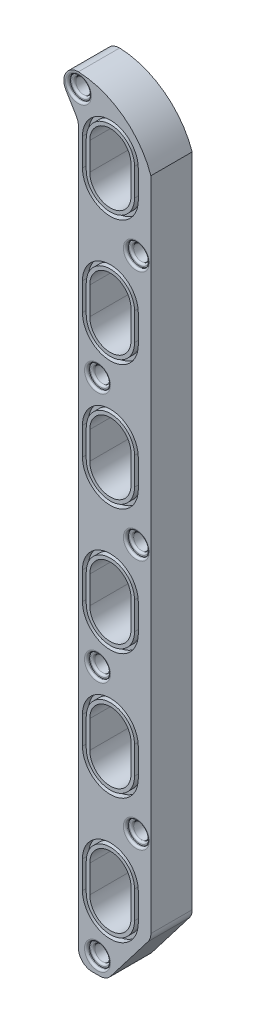
from build123d import *

# Parameters (mm, degrees)
BASE_FLANGE_GEOMETRY_R   = 5.6
BOSS_EXTRUDE1_DEPTH      = 4.35
BOSS_EXTRUDE1_2_DEPTH    = 4.35
BOSS_EXTRUDE1_3_DEPTH    = 4.35
BOSS_EXTRUDE1_4_DEPTH    = 4.35
BOSS_EXTRUDE1_5_DEPTH    = 4.35
BOSS_EXTRUDE1_6_DEPTH    = 4.35
BOSS_EXTRUDE1_7_DEPTH    = 4.35
BOSS_EXTRUDE2_START      = -25.65
BASE_FLANGE_GEOMETRY_5_R = 5.6
BOSS_EXTRUDE2_DEPTH      = 25.65
CHAMFER1_SIZE            = 42
CHAMFER1_SIZE2           = 32.227733495
FILLET1_R                = 10
CUT_EXTRUDE1_START       = -2.2
INSERT_HOLE_GEOMETRY_R   = 7.91
INSERT_HOLE_GEOMETRY_R_2 = 5.6
CUT_EXTRUDE1_DEPTH       = 2.2
FILLET2_R                = 1.5


with BuildPart() as part:
    # Base_Flange_Geometry → Boss-Extrude1 (new body)
    with BuildSketch(Plane(origin=(0, 0, 0), x_dir=(0, 1, 0), z_dir=(0, 0, 1))):
        with BuildLine():
            Line((245.4, 23.25), (-285, 23.25))
            Line((-285, 23.25), (-285, -29.45))
            Line((-285, -29.45), (237.5, -29.45))
            ThreePointArc((237.5, -29.45), (265.150364046, -9.109947518), (276.6, 23.25))
            ThreePointArc((276.6, 23.25), (271.222245174, 32.474324113), (260.545631068, 32.33899662))
            Line((260.545631068, 32.33899662), (245.4, 23.25))
        make_face()
        with Locations((-182, -18.85)):
            Circle(BASE_FLANGE_GEOMETRY_R, mode=Mode.SUBTRACT)
        with BuildLine():
            Line((-237.5, 20.3), (-217.5, 20.3))
            ThreePointArc((-217.5, 20.3), (-197.2, 0), (-217.5, -20.3))
            Line((-217.5, -20.3), (-237.5, -20.3))
            ThreePointArc((-237.5, -20.3), (-257.8, 0), (-237.5, 20.3))
        make_face(mode=Mode.SUBTRACT)
        with BuildLine():
            Line((-146.5, 20.3), (-126.5, 20.3))
            ThreePointArc((-126.5, 20.3), (-106.2, 0), (-126.5, -20.3))
            Line((-126.5, -20.3), (-146.5, -20.3))
            ThreePointArc((-146.5, -20.3), (-166.8, 0), (-146.5, 20.3))
        make_face(mode=Mode.SUBTRACT)
        with BuildLine():
            Line((-55.5, 20.3), (-35.5, 20.3))
            ThreePointArc((-35.5, 20.3), (-15.2, 0), (-35.5, -20.3))
            Line((-35.5, -20.3), (-55.5, -20.3))
            ThreePointArc((-55.5, -20.3), (-75.8, 0), (-55.5, 20.3))
        make_face(mode=Mode.SUBTRACT)
        with Locations((0, -18.85)):
            Circle(BASE_FLANGE_GEOMETRY_R, mode=Mode.SUBTRACT)
        with Locations((182, -18.85)):
            Circle(BASE_FLANGE_GEOMETRY_R, mode=Mode.SUBTRACT)
        with BuildLine():
            ThreePointArc((35.5, -20.3), (15.2, 0), (35.5, 20.3))
            Line((35.5, 20.3), (55.5, 20.3))
            ThreePointArc((55.5, 20.3), (75.8, 0), (55.5, -20.3))
            Line((55.5, -20.3), (35.5, -20.3))
        make_face(mode=Mode.SUBTRACT)
        with BuildLine():
            ThreePointArc((126.5, -20.3), (106.2, 0), (126.5, 20.3))
            Line((126.5, 20.3), (146.5, 20.3))
            ThreePointArc((146.5, 20.3), (166.8, 0), (146.5, -20.3))
            Line((146.5, -20.3), (126.5, -20.3))
        make_face(mode=Mode.SUBTRACT)
        with BuildLine():
            ThreePointArc((217.5, -20.3), (197.2, 0), (217.5, 20.3))
            Line((217.5, 20.3), (237.5, 20.3))
            ThreePointArc((237.5, 20.3), (257.8, 0), (237.5, -20.3))
            Line((237.5, -20.3), (217.5, -20.3))
        make_face(mode=Mode.SUBTRACT)
        with Locations((-273, 9.4)):
            Circle(BASE_FLANGE_GEOMETRY_R, mode=Mode.SUBTRACT)
        with Locations((-91, 9.4)):
            Circle(BASE_FLANGE_GEOMETRY_R, mode=Mode.SUBTRACT)
        with Locations((91, 9.4)):
            Circle(BASE_FLANGE_GEOMETRY_R, mode=Mode.SUBTRACT)
        with Locations((266, 23.25)):
            Circle(BASE_FLANGE_GEOMETRY_R, mode=Mode.SUBTRACT)
    extrude(amount=BOSS_EXTRUDE1_DEPTH)



with BuildPart() as body_2:
    # Base_Flange_Geometry → Boss-Extrude1 2 (new body)
    with BuildSketch(Plane(origin=(0, 0, 0), x_dir=(0, 1, 0), z_dir=(0, 0, 1))):
        with BuildLine():
            Line((237.5, 17.55), (217.5, 17.55))
            ThreePointArc((217.5, 17.55), (199.95, 0), (217.5, -17.55))
            Line((217.5, -17.55), (237.5, -17.55))
            ThreePointArc((237.5, -17.55), (255.05, 0), (237.5, 17.55))
        make_face()
        with BuildLine():
            ThreePointArc((217.5, -15), (202.5, 0), (217.5, 15))
            Line((217.5, 15), (237.5, 15))
            ThreePointArc((237.5, 15), (252.5, 0), (237.5, -15))
            Line((237.5, -15), (217.5, -15))
        make_face(mode=Mode.SUBTRACT)
    extrude(amount=BOSS_EXTRUDE1_2_DEPTH)


with BuildPart() as body_3:
    # Base_Flange_Geometry → Boss-Extrude1 3 (new body)
    with BuildSketch(Plane(origin=(0, 0, 0), x_dir=(0, 1, 0), z_dir=(0, 0, 1))):
        with BuildLine():
            Line((146.5, 17.55), (126.5, 17.55))
            ThreePointArc((126.5, 17.55), (108.95, 0), (126.5, -17.55))
            Line((126.5, -17.55), (146.5, -17.55))
            ThreePointArc((146.5, -17.55), (164.05, 0), (146.5, 17.55))
        make_face()
        with BuildLine():
            ThreePointArc((126.5, -15), (111.5, 0), (126.5, 15))
            Line((126.5, 15), (146.5, 15))
            ThreePointArc((146.5, 15), (161.5, 0), (146.5, -15))
            Line((146.5, -15), (126.5, -15))
        make_face(mode=Mode.SUBTRACT)
    extrude(amount=BOSS_EXTRUDE1_3_DEPTH)


with BuildPart() as body_4:
    # Base_Flange_Geometry → Boss-Extrude1 4 (new body)
    with BuildSketch(Plane(origin=(0, 0, 0), x_dir=(0, 1, 0), z_dir=(0, 0, 1))):
        with BuildLine():
            Line((55.5, 17.55), (35.5, 17.55))
            ThreePointArc((35.5, 17.55), (17.95, 0), (35.5, -17.55))
            Line((35.5, -17.55), (55.5, -17.55))
            ThreePointArc((55.5, -17.55), (73.05, 0), (55.5, 17.55))
        make_face()
        with BuildLine():
            ThreePointArc((35.5, -15), (20.5, 0), (35.5, 15))
            Line((35.5, 15), (55.5, 15))
            ThreePointArc((55.5, 15), (70.5, 0), (55.5, -15))
            Line((55.5, -15), (35.5, -15))
        make_face(mode=Mode.SUBTRACT)
    extrude(amount=BOSS_EXTRUDE1_4_DEPTH)


with BuildPart() as body_5:
    # Base_Flange_Geometry → Boss-Extrude1 5 (new body)
    with BuildSketch(Plane(origin=(0, 0, 0), x_dir=(0, 1, 0), z_dir=(0, 0, 1))):
        with BuildLine():
            ThreePointArc((-35.5, -17.55), (-17.95, 0), (-35.5, 17.55))
            Line((-35.5, 17.55), (-55.5, 17.55))
            ThreePointArc((-55.5, 17.55), (-73.05, 0), (-55.5, -17.55))
            Line((-55.5, -17.55), (-35.5, -17.55))
        make_face()
        with BuildLine():
            Line((-55.5, 15), (-35.5, 15))
            ThreePointArc((-35.5, 15), (-20.5, 0), (-35.5, -15))
            Line((-35.5, -15), (-55.5, -15))
            ThreePointArc((-55.5, -15), (-70.5, 0), (-55.5, 15))
        make_face(mode=Mode.SUBTRACT)
    extrude(amount=BOSS_EXTRUDE1_5_DEPTH)


with BuildPart() as body_6:
    # Base_Flange_Geometry → Boss-Extrude1 6 (new body)
    with BuildSketch(Plane(origin=(0, 0, 0), x_dir=(0, 1, 0), z_dir=(0, 0, 1))):
        with BuildLine():
            ThreePointArc((-126.5, -17.55), (-108.95, 0), (-126.5, 17.55))
            Line((-126.5, 17.55), (-146.5, 17.55))
            ThreePointArc((-146.5, 17.55), (-164.05, 0), (-146.5, -17.55))
            Line((-146.5, -17.55), (-126.5, -17.55))
        make_face()
        with BuildLine():
            Line((-146.5, 15), (-126.5, 15))
            ThreePointArc((-126.5, 15), (-111.5, 0), (-126.5, -15))
            Line((-126.5, -15), (-146.5, -15))
            ThreePointArc((-146.5, -15), (-161.5, 0), (-146.5, 15))
        make_face(mode=Mode.SUBTRACT)
    extrude(amount=BOSS_EXTRUDE1_6_DEPTH)


with BuildPart() as body_7:
    # Base_Flange_Geometry → Boss-Extrude1 7 (new body)
    with BuildSketch(Plane(origin=(0, 0, 0), x_dir=(0, 1, 0), z_dir=(0, 0, 1))):
        with BuildLine():
            ThreePointArc((-217.5, -17.55), (-199.95, 0), (-217.5, 17.55))
            Line((-217.5, 17.55), (-237.5, 17.55))
            ThreePointArc((-237.5, 17.55), (-255.05, 0), (-237.5, -17.55))
            Line((-237.5, -17.55), (-217.5, -17.55))
        make_face()
        with BuildLine():
            Line((-237.5, 15), (-217.5, 15))
            ThreePointArc((-217.5, 15), (-202.5, 0), (-217.5, -15))
            Line((-217.5, -15), (-237.5, -15))
            ThreePointArc((-237.5, -15), (-252.5, 0), (-237.5, 15))
        make_face(mode=Mode.SUBTRACT)
    extrude(amount=BOSS_EXTRUDE1_7_DEPTH)


with BuildPart() as part_1:
    add(part.part)

    add(body_2.part)  # Boss-Extrude2 merges body 2

    add(body_3.part)  # Boss-Extrude2 merges body 3

    add(body_4.part)  # Boss-Extrude2 merges body 4

    add(body_5.part)  # Boss-Extrude2 merges body 5

    add(body_6.part)  # Boss-Extrude2 merges body 6

    add(body_7.part)  # Boss-Extrude2 merges body 7
    # Base_Flange_Geometry_5 → Boss-Extrude2 (add)
    with BuildSketch(Plane(origin=(0, 0, 0), x_dir=(0, 1, 0), z_dir=(0, 0, 1)).offset(BOSS_EXTRUDE2_START)):
        with BuildLine():
            Line((245.4, 23.25), (-285, 23.25))
            Line((-285, 23.25), (-285, -29.45))
            Line((-285, -29.45), (237.5, -29.45))
            ThreePointArc((237.5, -29.45), (265.150364046, -9.109947518), (276.6, 23.25))
            ThreePointArc((276.6, 23.25), (271.222245174, 32.474324113), (260.545631068, 32.33899662))
            Line((260.545631068, 32.33899662), (245.4, 23.25))
        make_face()
        with Locations((-182, -18.85)):
            Circle(BASE_FLANGE_GEOMETRY_5_R, mode=Mode.SUBTRACT)
        with Locations((0, -18.85)):
            Circle(BASE_FLANGE_GEOMETRY_5_R, mode=Mode.SUBTRACT)
        with Locations((182, -18.85)):
            Circle(BASE_FLANGE_GEOMETRY_5_R, mode=Mode.SUBTRACT)
        with Locations((-273, 9.4)):
            Circle(BASE_FLANGE_GEOMETRY_5_R, mode=Mode.SUBTRACT)
        with Locations((-91, 9.4)):
            Circle(BASE_FLANGE_GEOMETRY_5_R, mode=Mode.SUBTRACT)
        with Locations((91, 9.4)):
            Circle(BASE_FLANGE_GEOMETRY_5_R, mode=Mode.SUBTRACT)
        with Locations((266, 23.25)):
            Circle(BASE_FLANGE_GEOMETRY_5_R, mode=Mode.SUBTRACT)
        with BuildLine():
            Line((-237.5, 15), (-217.5, 15))
            ThreePointArc((-217.5, 15), (-202.5, 0), (-217.5, -15))
            Line((-217.5, -15), (-237.5, -15))
            ThreePointArc((-237.5, -15), (-252.5, 0), (-237.5, 15))
        make_face(mode=Mode.SUBTRACT)
        with BuildLine():
            Line((-146.5, 15), (-126.5, 15))
            ThreePointArc((-126.5, 15), (-111.5, 0), (-126.5, -15))
            Line((-126.5, -15), (-146.5, -15))
            ThreePointArc((-146.5, -15), (-161.5, 0), (-146.5, 15))
        make_face(mode=Mode.SUBTRACT)
        with BuildLine():
            Line((-55.5, 15), (-35.5, 15))
            ThreePointArc((-35.5, 15), (-20.5, 0), (-35.5, -15))
            Line((-35.5, -15), (-55.5, -15))
            ThreePointArc((-55.5, -15), (-70.5, 0), (-55.5, 15))
        make_face(mode=Mode.SUBTRACT)
        with BuildLine():
            ThreePointArc((35.5, -15), (20.5, 0), (35.5, 15))
            Line((35.5, 15), (55.5, 15))
            ThreePointArc((55.5, 15), (70.5, 0), (55.5, -15))
            Line((55.5, -15), (35.5, -15))
        make_face(mode=Mode.SUBTRACT)
        with BuildLine():
            ThreePointArc((126.5, -15), (111.5, 0), (126.5, 15))
            Line((126.5, 15), (146.5, 15))
            ThreePointArc((146.5, 15), (161.5, 0), (146.5, -15))
            Line((146.5, -15), (126.5, -15))
        make_face(mode=Mode.SUBTRACT)
        with BuildLine():
            ThreePointArc((217.5, -15), (202.5, 0), (217.5, 15))
            Line((217.5, 15), (237.5, 15))
            ThreePointArc((237.5, 15), (252.5, 0), (237.5, -15))
            Line((237.5, -15), (217.5, -15))
        make_face(mode=Mode.SUBTRACT)
    extrude(amount=BOSS_EXTRUDE2_DEPTH)

    # Chamfer1
    chamfer1_edges = [part_1.edges().sort_by_distance(p)[0] for p in [
        (29.45, -285, -10.65),
    ]]
    chamfer1_side = [part_1.faces().sort_by_distance(p)[0] for p in [
        (29.45, -23.75, -10.65),
    ]]
    chamfer(chamfer1_edges, length=CHAMFER1_SIZE, length2=CHAMFER1_SIZE2, reference=chamfer1_side[0])

    # Fillet1
    fillet1_edges = [part_1.edges().sort_by_distance(p)[0] for p in [
        (-2.777733495, -285, -10.65),
        (-23.25, -285, -10.65),
        (-23.25, 245.4, -10.65),
        (29.45, -243, -10.65),
    ]]
    fillet(fillet1_edges, radius=FILLET1_R)

    # Insert_Hole_Geometry → Cut-Extrude1 (cut)
    # profile 1 of 7: a face of its own
    with BuildSketch(Plane.XY.offset(4.35).offset(CUT_EXTRUDE1_START)):
        with Locations((18.85, 182)):
            Circle(INSERT_HOLE_GEOMETRY_R)
        with Locations((18.85, 182)):
            Circle(INSERT_HOLE_GEOMETRY_R_2, mode=Mode.SUBTRACT)
    # profile 2 of 7: a face of its own
    with BuildSketch(Plane.XY.offset(4.35).offset(CUT_EXTRUDE1_START)):
        with Locations((-23.25, 266)):
            Circle(INSERT_HOLE_GEOMETRY_R)
        with Locations((-23.25, 266)):
            Circle(INSERT_HOLE_GEOMETRY_R_2, mode=Mode.SUBTRACT)
    # profile 3 of 7: a face of its own
    with BuildSketch(Plane.XY.offset(4.35).offset(CUT_EXTRUDE1_START)):
        with Locations((-9.4, 91)):
            Circle(INSERT_HOLE_GEOMETRY_R)
        with Locations((-9.4, 91)):
            Circle(INSERT_HOLE_GEOMETRY_R_2, mode=Mode.SUBTRACT)
    # profile 4 of 7: a face of its own
    with BuildSketch(Plane.XY.offset(4.35).offset(CUT_EXTRUDE1_START)):
        with Locations((18.85, 0)):
            Circle(INSERT_HOLE_GEOMETRY_R)
        with Locations((18.85, 0)):
            Circle(INSERT_HOLE_GEOMETRY_R_2, mode=Mode.SUBTRACT)
    # profile 5 of 7: a face of its own
    with BuildSketch(Plane.XY.offset(4.35).offset(CUT_EXTRUDE1_START)):
        with Locations((-9.4, -91)):
            Circle(INSERT_HOLE_GEOMETRY_R)
        with Locations((-9.4, -91)):
            Circle(INSERT_HOLE_GEOMETRY_R_2, mode=Mode.SUBTRACT)
    # profile 6 of 7: a face of its own
    with BuildSketch(Plane.XY.offset(4.35).offset(CUT_EXTRUDE1_START)):
        with Locations((18.85, -182)):
            Circle(INSERT_HOLE_GEOMETRY_R)
        with Locations((18.85, -182)):
            Circle(INSERT_HOLE_GEOMETRY_R_2, mode=Mode.SUBTRACT)
    # profile 7 of 7: a face of its own
    with BuildSketch(Plane.XY.offset(4.35).offset(CUT_EXTRUDE1_START)):
        with Locations((-9.4, -273)):
            Circle(INSERT_HOLE_GEOMETRY_R)
        with Locations((-9.4, -273)):
            Circle(INSERT_HOLE_GEOMETRY_R_2, mode=Mode.SUBTRACT)
    extrude(amount=CUT_EXTRUDE1_DEPTH, mode=Mode.SUBTRACT)

    # Fillet2
    fillet2_edges = [part_1.edges().sort_by_distance(p)[0] for p in [
        (-31.16, 266, 4.35),
        (10.94, 182, 4.35),
        (-17.31, 91, 4.35),
        (10.94, 0, 4.35),
        (-17.31, -273, 4.35),
        (10.94, -182, 4.35),
        (-17.31, -91, 4.35),
        (-9.4, -96.6, 2.15),
        (-9.4, -278.6, 2.15),
        (18.85, -187.6, 2.15),
        (-23.25, 260.4, 2.15),
        (18.85, 176.4, 2.15),
        (-9.4, 85.4, 2.15),
        (18.85, -5.6, 2.15),
    ]]
    fillet(fillet2_edges, radius=FILLET2_R)


solid = part_1.part
